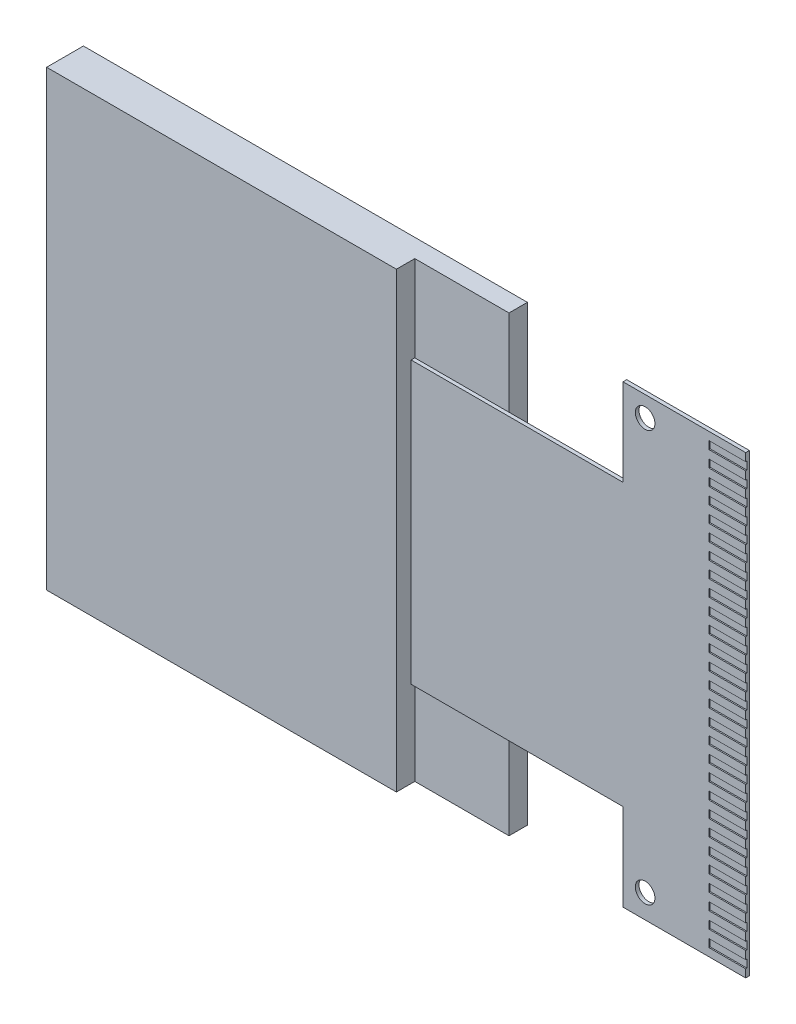
from build123d import *

# Parameters (mm, degrees)
SKETCH1_W           = 18.1
SKETCH1_H           = 18.46
BOSS_EXTRUDE1_DEPTH = 1.5
SKETCH2_W           = 3.84
SKETCH2_H           = 18.46
CUT_EXTRUDE1_DEPTH  = 0.75
BOSS_EXTRUDE2_DEPTH = 0.15
SKETCH4_R           = 0.4
CUT_EXTRUDE2_DEPTH  = 0.15
SKETCH5_W           = 1.5
SKETCH5_H           = 0.32
CUT_EXTRUDE6_DEPTH  = 0.05


with BuildPart() as part:
    # Sketch1 → Boss-Extrude1 (new body)
    with BuildSketch(Plane.XY):
        with Locations((9.05, 9.23)):
            Rectangle(SKETCH1_W, SKETCH1_H)
    extrude(amount=BOSS_EXTRUDE1_DEPTH)

    # Sketch2 → Cut-Extrude1 (cut)
    with BuildSketch(Plane.XY.offset(1.5)):
        with Locations((16.18, 9.23)):
            Rectangle(SKETCH2_W, SKETCH2_H)
    extrude(amount=-CUT_EXTRUDE1_DEPTH, mode=Mode.SUBTRACT)


with BuildPart() as body_2:
    # Sketch3 → Boss-Extrude2 (new body)
    with BuildSketch(Plane.XY.offset(0.75)):
        Polygon((22.9, 18.505), (27.9, 18.505), (27.9, -0.045), (22.9, -0.045), (22.9, 3.505), (14.26, 3.505), (14.26, 14.955), (22.9, 14.955), align=None)
    extrude(amount=BOSS_EXTRUDE2_DEPTH)

    # Sketch4 → Cut-Extrude2 (cut)
    with BuildSketch(Plane.XY.offset(0.9)):
        with Locations((23.8, 17.675)):
            Circle(SKETCH4_R)
        with Locations((23.8, 0.925)):
            Circle(SKETCH4_R)
    extrude(amount=-CUT_EXTRUDE2_DEPTH, mode=Mode.SUBTRACT)

    # Sketch5 → Cut-Extrude6 (cut)
    with BuildSketch(Plane.XY.offset(0.9)):
        with Locations((27.15, 0.438659377)):
            Rectangle(SKETCH5_W, SKETCH5_H)
        with Locations((27.15, 1.089869794)):
            Rectangle(SKETCH5_W, SKETCH5_H)
        with Locations((27.15, 1.74108021)):
            Rectangle(SKETCH5_W, SKETCH5_H)
        with Locations((27.15, 2.392290627)):
            Rectangle(SKETCH5_W, SKETCH5_H)
        with Locations((27.15, 3.043501043)):
            Rectangle(SKETCH5_W, SKETCH5_H)
        with Locations((27.15, 3.69471146)):
            Rectangle(SKETCH5_W, SKETCH5_H)
        with Locations((27.15, 4.345921876)):
            Rectangle(SKETCH5_W, SKETCH5_H)
        with Locations((27.15, 4.997132293)):
            Rectangle(SKETCH5_W, SKETCH5_H)
        with Locations((27.15, 5.648342709)):
            Rectangle(SKETCH5_W, SKETCH5_H)
        with Locations((27.15, 6.299553126)):
            Rectangle(SKETCH5_W, SKETCH5_H)
        with Locations((27.15, 6.950763542)):
            Rectangle(SKETCH5_W, SKETCH5_H)
        with Locations((27.15, 7.601973959)):
            Rectangle(SKETCH5_W, SKETCH5_H)
        with Locations((27.15, 8.253184375)):
            Rectangle(SKETCH5_W, SKETCH5_H)
        with Locations((27.15, 8.904394792)):
            Rectangle(SKETCH5_W, SKETCH5_H)
        with Locations((27.15, 9.555605208)):
            Rectangle(SKETCH5_W, SKETCH5_H)
        with Locations((27.15, 10.206815625)):
            Rectangle(SKETCH5_W, SKETCH5_H)
        with Locations((27.15, 10.858026041)):
            Rectangle(SKETCH5_W, SKETCH5_H)
        with Locations((27.15, 11.509236458)):
            Rectangle(SKETCH5_W, SKETCH5_H)
        with Locations((27.15, 12.160446874)):
            Rectangle(SKETCH5_W, SKETCH5_H)
        with Locations((27.15, 12.811657291)):
            Rectangle(SKETCH5_W, SKETCH5_H)
        with Locations((27.15, 13.462867707)):
            Rectangle(SKETCH5_W, SKETCH5_H)
        with Locations((27.15, 14.114078124)):
            Rectangle(SKETCH5_W, SKETCH5_H)
        with Locations((27.15, 14.76528854)):
            Rectangle(SKETCH5_W, SKETCH5_H)
        with Locations((27.15, 15.416498957)):
            Rectangle(SKETCH5_W, SKETCH5_H)
        with Locations((27.15, 16.067709373)):
            Rectangle(SKETCH5_W, SKETCH5_H)
        with Locations((27.15, 16.71891979)):
            Rectangle(SKETCH5_W, SKETCH5_H)
        with Locations((27.15, 17.370130206)):
            Rectangle(SKETCH5_W, SKETCH5_H)
        with Locations((27.15, 18.021340623)):
            Rectangle(SKETCH5_W, SKETCH5_H)
    extrude(amount=-CUT_EXTRUDE6_DEPTH, mode=Mode.SUBTRACT)


solid = Compound([part.part, body_2.part])
